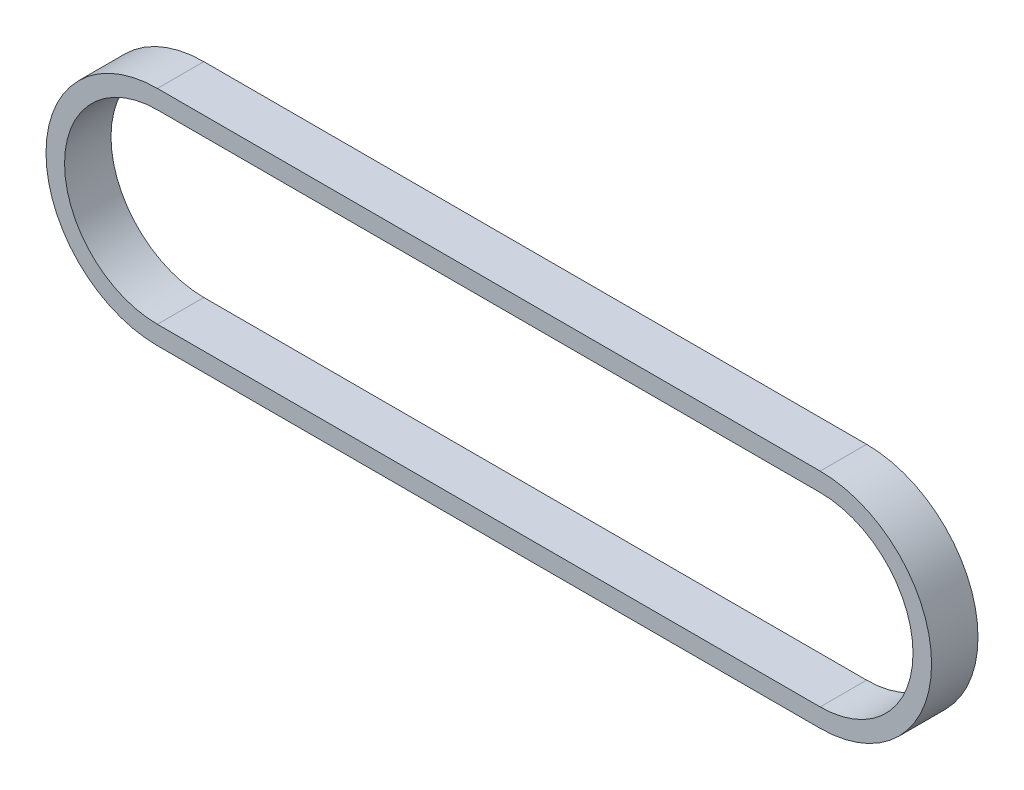
from build123d import *

# Parameters (mm, degrees)
BOSS_EXTRUDE1_DEPTH = 6.35


with BuildPart() as part:
    # Sketch1 → Boss-Extrude1 (new body)
    with BuildSketch(Plane.XY):
        with BuildLine():
            Line((0, 15.24), (90.66149, 15.24))
            ThreePointArc((90.66149, 15.24), (105.90149, 0), (90.66149, -15.24))
            Line((90.66149, -15.24), (0, -15.24))
            ThreePointArc((0, -15.24), (-15.24, 0), (0, 15.24))
        make_face()
        with BuildLine():
            Line((0, 12.7), (90.66149, 12.7))
            ThreePointArc((90.66149, 12.7), (103.36149, 0), (90.66149, -12.7))
            Line((90.66149, -12.7), (0, -12.7))
            ThreePointArc((0, -12.7), (-12.7, 0), (0, 12.7))
        make_face(mode=Mode.SUBTRACT)
    extrude(amount=BOSS_EXTRUDE1_DEPTH)


solid = part.part
